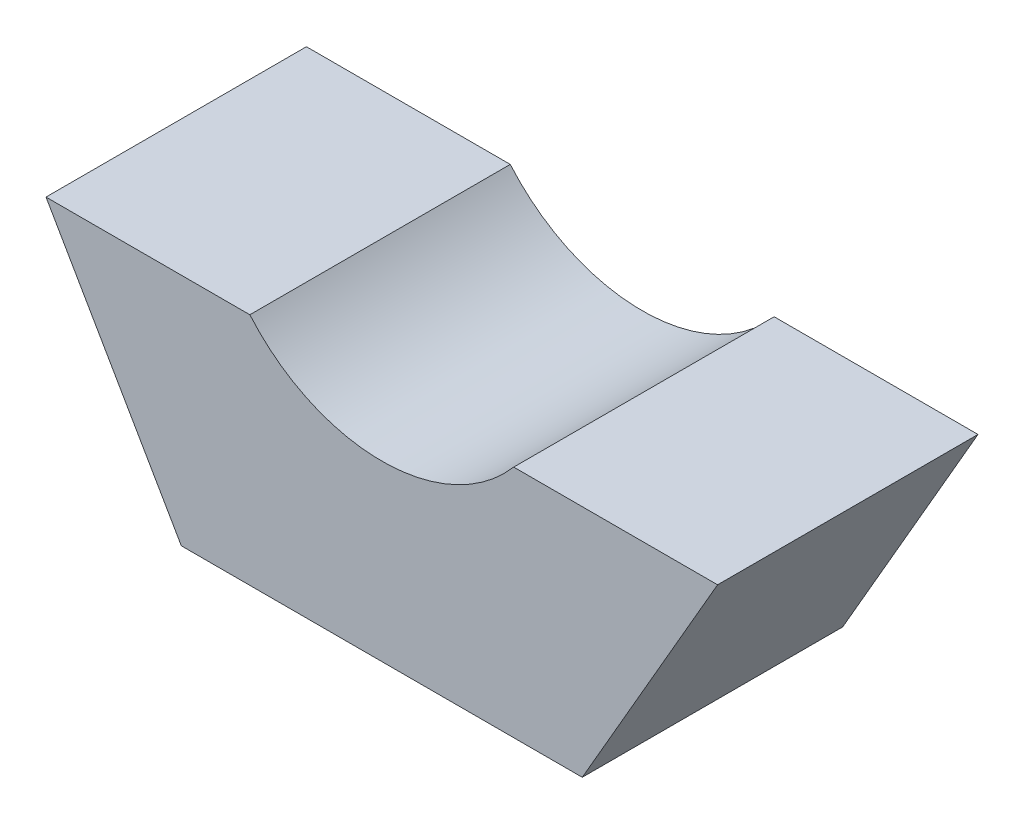
from build123d import *

# Parameters (mm, degrees)
SKETCH_1_R          = 20
EXTRUDE_1_DEPTH     = 30
SKETCH_2_W          = 102.73425285
SKETCH_2_H          = 41.168069265
CUT_EXTRUDE_1_DEPTH = 89
SKETCH_3_W          = 92.921845771
SKETCH_3_H          = 3
CUT_EXTRUDE_2_DEPTH = 89
SKETCH_5_W          = 89.254796613
SKETCH_5_H          = 10
CUT_EXTRUDE_3_DEPTH = 31


with BuildPart() as part:
    # 스케치1 → 보스-돌출1 (new body)
    with BuildSketch(Plane.XY):
        Polygon((46.188021535, 0), (23.094010768, 40), (-23.094010768, 40), (-46.188021535, 0), (-23.094010768, -40), (23.094010768, -40), align=None)
        Circle(SKETCH_1_R, mode=Mode.SUBTRACT)
    extrude(amount=EXTRUDE_1_DEPTH)

    # 스케치2 → 컷-돌출1 (cut)
    with BuildSketch(Plane.XY):
        with Locations((0.690561162, 20.584034632)):
            Rectangle(SKETCH_2_W, SKETCH_2_H)
    extrude(amount=CUT_EXTRUDE_1_DEPTH, mode=Mode.SUBTRACT)

    # 스케치3 → 컷-돌출2 (cut)
    with BuildSketch(Plane.XY.offset(30)):
        with Locations((-0.27290135, -1.5)):
            Rectangle(SKETCH_3_W, SKETCH_3_H)
    extrude(amount=-CUT_EXTRUDE_2_DEPTH, mode=Mode.SUBTRACT)

    # 스케치5 → 컷-돌출3 (cut, through all)
    with BuildSketch(Plane.XY.offset(30)):
        with Locations((-0.171427578, -8)):
            Rectangle(SKETCH_5_W, SKETCH_5_H)
    extrude(amount=-CUT_EXTRUDE_3_DEPTH, mode=Mode.SUBTRACT)


solid = part.part
